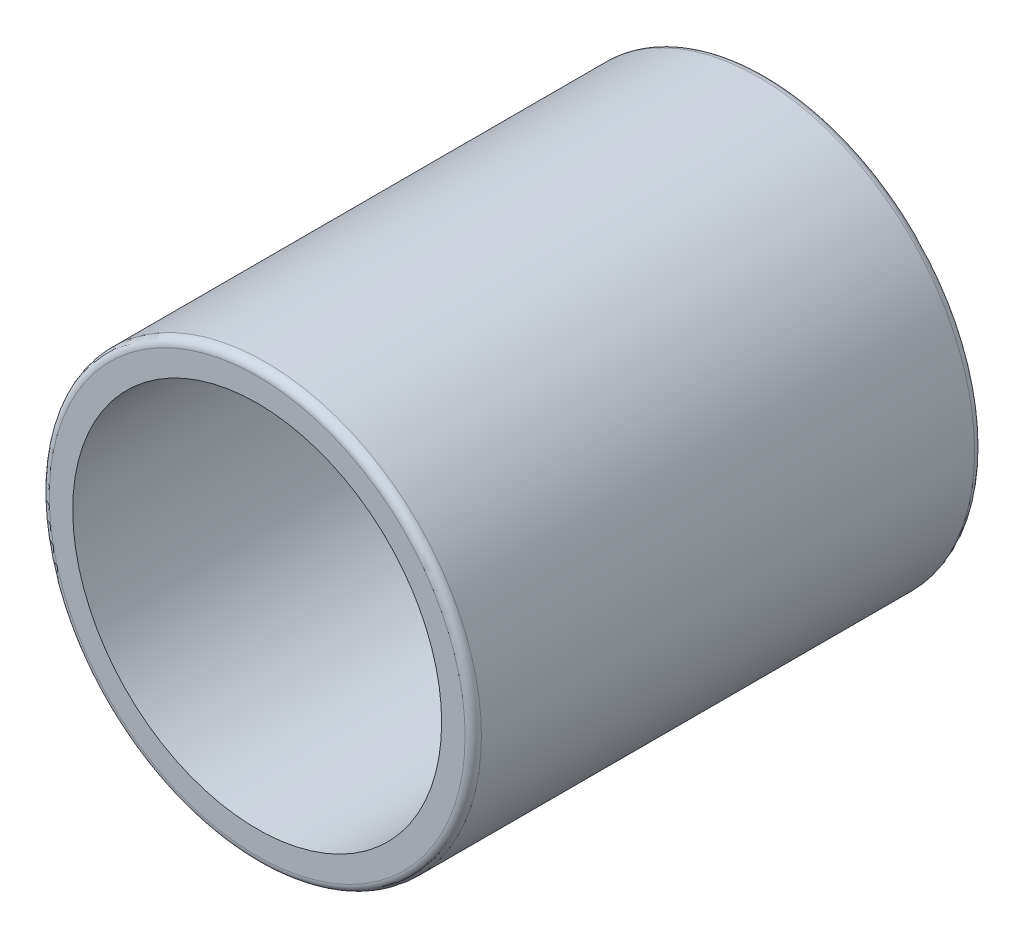
from build123d import *

# Parameters (mm, degrees)
SKETCH_1_R          = 5.3
SKETCH_1_R_2        = 4.525
EXTRUDE_1_DEPTH     = 12.5
SKETCH_2_R          = 2.5
SKETCH_2_W          = 3.970430226
SKETCH_2_H          = 5
CUT_EXTRUDE_1_DEPTH = 12.5
FILLET_1_R          = 0.2


with BuildPart() as part:
    # 草图1 → 凸台-拉伸1 (new body)
    with BuildSketch(Plane.XY):
        Circle(SKETCH_1_R)
        Circle(SKETCH_1_R_2, mode=Mode.SUBTRACT)
    extrude(amount=EXTRUDE_1_DEPTH)

    # 草图2 → 切除-拉伸1 (cut)
    with BuildSketch(Plane(origin=(0, 0, 0), x_dir=(0, 0, -1), z_dir=(1, 0, 0))):
        with Locations((-3, 0)):
            Circle(SKETCH_2_R)
        with Locations((-1.014784887, 0)):
            Rectangle(SKETCH_2_W, SKETCH_2_H)
    extrude(amount=-CUT_EXTRUDE_1_DEPTH, mode=Mode.SUBTRACT)

    # 圆角1
    fillet_1_edges = [part.edges().sort_by_distance(p)[0] for p in [
        (1.288673453, 5.14094551, 0),
        (-5.3, 0, 12.5),
    ]]
    fillet(fillet_1_edges, radius=FILLET_1_R)


solid = part.part
